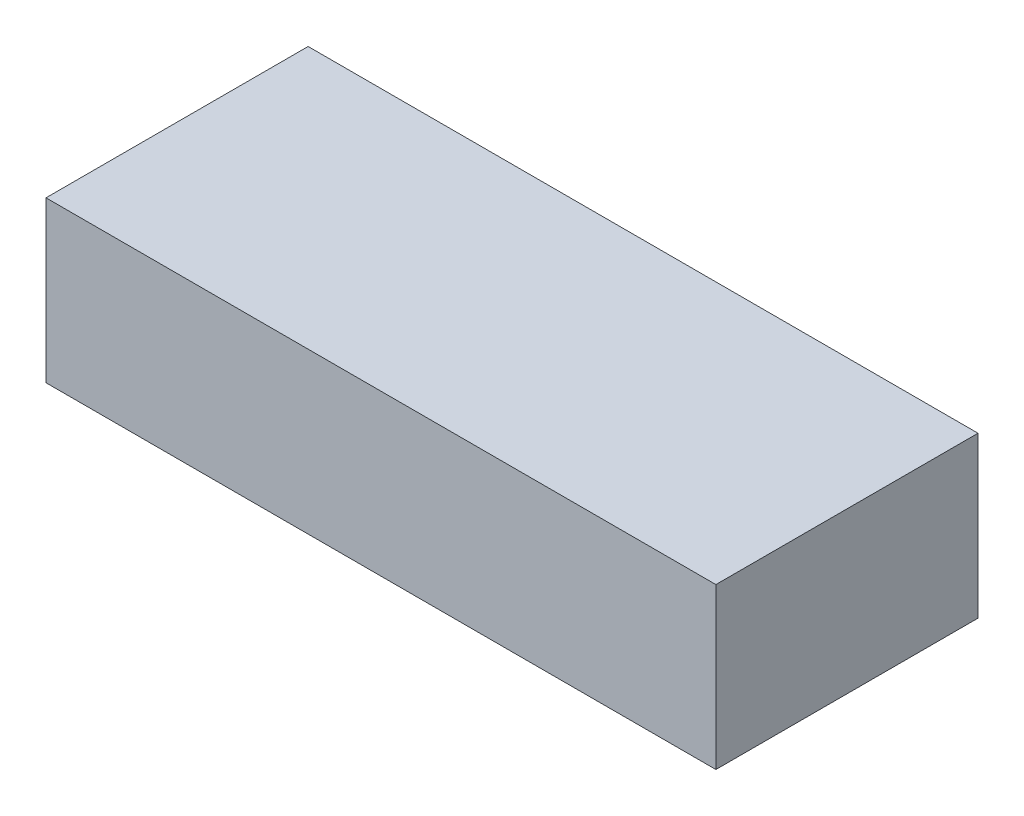
from build123d import *

# Parameters (mm, degrees)
SKETCH1_W           = 13.8
SKETCH1_H           = 5.4
BOSS_EXTRUDE1_DEPTH = 3.3


with BuildPart() as part:
    # Sketch1 → Boss-Extrude1 (new body)
    with BuildSketch(Plane(origin=(0, 0, 0), x_dir=(1, 0, 0), z_dir=(0, 1, 0))):
        Rectangle(SKETCH1_W, SKETCH1_H)
    extrude(amount=BOSS_EXTRUDE1_DEPTH)


solid = part.part
